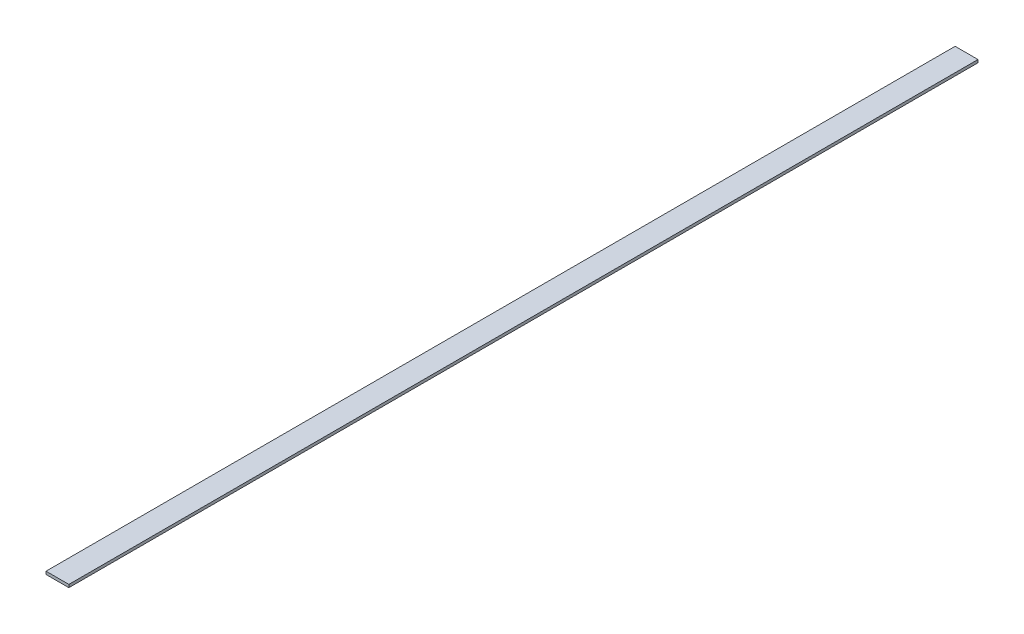
from build123d import *

# Parameters (mm, degrees)
SKETCH1_W           = 12.7
SKETCH1_H           = 505
BOSS_EXTRUDE1_DEPTH = 1.59


with BuildPart() as part:
    # Sketch1 → Boss-Extrude1 (new body)
    with BuildSketch(Plane(origin=(0, 0, 0), x_dir=(1, 0, 0), z_dir=(0, 1, 0))):
        with Locations((6.35, 252.5)):
            Rectangle(SKETCH1_W, SKETCH1_H)
    extrude(amount=BOSS_EXTRUDE1_DEPTH)


solid = part.part
